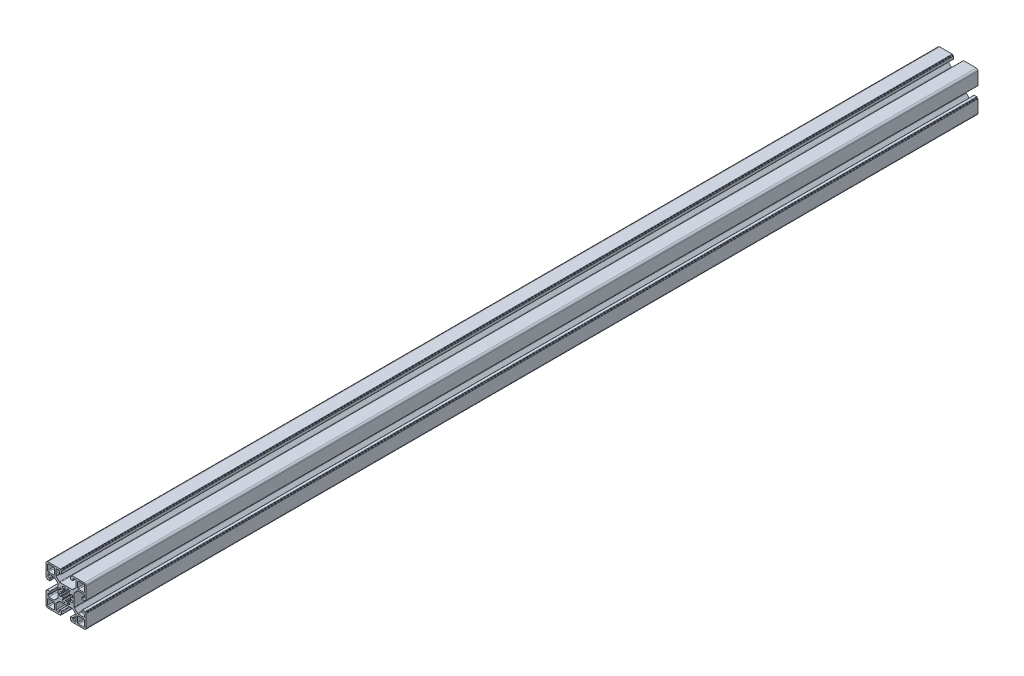
from build123d import *

# Parameters (mm, degrees)
EXTRUDE_1_DEPTH = 1000


with BuildPart() as part:
    # Эскиз1 → Бобышка-Вытянуть1 (new body)
    with BuildSketch(Plane.XY):
        with BuildLine():
            Line((-22.5, 11.25), (-22.5, 20.5))
            ThreePointArc((-22.5, 20.5), (-21.914213562, 21.914213562), (-20.5, 22.5))
            Line((-20.5, 22.5), (-11.25, 22.5))
            Line((-11.25, 22.5), (-6.4, 22.5))
            ThreePointArc((-6.4, 22.5), (-6.187867966, 22.412132034), (-6.1, 22.2))
            Line((-6.1, 22.2), (-6.1, 21.8))
            ThreePointArc((-6.1, 21.8), (-6.012132034, 21.587867966), (-5.8, 21.5))
            Line((-5.8, 21.5), (-5.4, 21.5))
            ThreePointArc((-5.4, 21.5), (-5.187867966, 21.412132034), (-5.1, 21.2))
            Line((-5.1, 21.2), (-5.1, 18.3))
            ThreePointArc((-5.1, 18.3), (-5.187867966, 18.087867966), (-5.4, 18))
            Line((-5.4, 18), (-7.3, 18))
            ThreePointArc((-7.3, 18), (-7.512132034, 18.087867966), (-7.6, 18.3))
            Line((-7.6, 18.3), (-7.6, 19.5))
            ThreePointArc((-7.6, 19.5), (-7.892893219, 20.207106781), (-8.6, 20.5))
            Line((-8.6, 20.5), (-10.25, 20.5))
            ThreePointArc((-10.25, 20.5), (-10.957106781, 20.207106781), (-11.25, 19.5))
            Line((-11.25, 19.5), (-11.25, 13.564213562))
            ThreePointArc((-11.25, 13.564213562), (-11.173879533, 13.18153013), (-10.957106781, 12.857106781))
            Line((-10.957106781, 12.857106781), (-7.542893219, 9.442893219))
            ThreePointArc((-7.542893219, 9.442893219), (-7.21846987, 9.226120467), (-6.835786438, 9.15))
            Line((-6.835786438, 9.15), (6.835786438, 9.15))
            ThreePointArc((6.835786438, 9.15), (7.21846987, 9.226120467), (7.542893219, 9.442893219))
            Line((7.542893219, 9.442893219), (10.957106781, 12.857106781))
            ThreePointArc((10.957106781, 12.857106781), (11.173879533, 13.18153013), (11.25, 13.564213562))
            Line((11.25, 13.564213562), (11.25, 19.5))
            ThreePointArc((11.25, 19.5), (10.957106781, 20.207106781), (10.25, 20.5))
            Line((10.25, 20.5), (8.6, 20.5))
            ThreePointArc((8.6, 20.5), (7.892893219, 20.207106781), (7.6, 19.5))
            Line((7.6, 19.5), (7.6, 18.3))
            ThreePointArc((7.6, 18.3), (7.512132034, 18.087867966), (7.3, 18))
            Line((7.3, 18), (5.4, 18))
            ThreePointArc((5.4, 18), (5.187867966, 18.087867966), (5.1, 18.3))
            Line((5.1, 18.3), (5.1, 21.2))
            ThreePointArc((5.1, 21.2), (5.187867966, 21.412132034), (5.4, 21.5))
            Line((5.4, 21.5), (5.8, 21.5))
            ThreePointArc((5.8, 21.5), (6.012132034, 21.587867966), (6.1, 21.8))
            Line((6.1, 21.8), (6.1, 22.2))
            ThreePointArc((6.1, 22.2), (6.187867966, 22.412132034), (6.4, 22.5))
            Line((6.4, 22.5), (11.25, 22.5))
            Line((11.25, 22.5), (20.5, 22.5))
            ThreePointArc((20.5, 22.5), (21.914213562, 21.914213562), (22.5, 20.5))
            Line((22.5, 20.5), (22.5, 11.25))
            Line((22.5, 11.25), (22.5, 6.4))
            ThreePointArc((22.5, 6.4), (22.412132034, 6.187867966), (22.2, 6.1))
            Line((22.2, 6.1), (21.8, 6.1))
            ThreePointArc((21.8, 6.1), (21.587867966, 6.012132034), (21.5, 5.8))
            Line((21.5, 5.8), (21.5, 5.4))
            ThreePointArc((21.5, 5.4), (21.412132034, 5.187867966), (21.2, 5.1))
            Line((21.2, 5.1), (18.3, 5.1))
            ThreePointArc((18.3, 5.1), (18.087867966, 5.187867966), (18, 5.4))
            Line((18, 5.4), (18, 7.3))
            ThreePointArc((18, 7.3), (18.087867966, 7.512132034), (18.3, 7.6))
            Line((18.3, 7.6), (19.5, 7.6))
            ThreePointArc((19.5, 7.6), (20.207106781, 7.892893219), (20.5, 8.6))
            Line((20.5, 8.6), (20.5, 10.25))
            ThreePointArc((20.5, 10.25), (20.207106781, 10.957106781), (19.5, 11.25))
            Line((19.5, 11.25), (13.564213562, 11.25))
            ThreePointArc((13.564213562, 11.25), (13.18153013, 11.173879533), (12.857106781, 10.957106781))
            Line((12.857106781, 10.957106781), (9.442893219, 7.542893219))
            ThreePointArc((9.442893219, 7.542893219), (9.226120467, 7.21846987), (9.15, 6.835786438))
            Line((9.15, 6.835786438), (9.15, -6.835786438))
            ThreePointArc((9.15, -6.835786438), (9.226120467, -7.21846987), (9.442893219, -7.542893219))
            Line((9.442893219, -7.542893219), (12.857106781, -10.957106781))
            ThreePointArc((12.857106781, -10.957106781), (13.18153013, -11.173879533), (13.564213562, -11.25))
            Line((13.564213562, -11.25), (19.5, -11.25))
            ThreePointArc((19.5, -11.25), (20.207106781, -10.957106781), (20.5, -10.25))
            Line((20.5, -10.25), (20.5, -8.6))
            ThreePointArc((20.5, -8.6), (20.207106781, -7.892893219), (19.5, -7.6))
            Line((19.5, -7.6), (18.3, -7.6))
            ThreePointArc((18.3, -7.6), (18.087867966, -7.512132034), (18, -7.3))
            Line((18, -7.3), (18, -5.4))
            ThreePointArc((18, -5.4), (18.087867966, -5.187867966), (18.3, -5.1))
            Line((18.3, -5.1), (21.2, -5.1))
            ThreePointArc((21.2, -5.1), (21.412132034, -5.187867966), (21.5, -5.4))
            Line((21.5, -5.4), (21.5, -5.8))
            ThreePointArc((21.5, -5.8), (21.587867966, -6.012132034), (21.8, -6.1))
            Line((21.8, -6.1), (22.2, -6.1))
            ThreePointArc((22.2, -6.1), (22.412132034, -6.187867966), (22.5, -6.4))
            Line((22.5, -6.4), (22.5, -11.25))
            Line((22.5, -11.25), (22.5, -20.5))
            ThreePointArc((22.5, -20.5), (21.914213562, -21.914213562), (20.5, -22.5))
            Line((20.5, -22.5), (11.25, -22.5))
            Line((11.25, -22.5), (6.4, -22.5))
            ThreePointArc((6.4, -22.5), (6.187867966, -22.412132034), (6.1, -22.2))
            Line((6.1, -22.2), (6.1, -21.8))
            ThreePointArc((6.1, -21.8), (6.012132034, -21.587867966), (5.8, -21.5))
            Line((5.8, -21.5), (5.4, -21.5))
            ThreePointArc((5.4, -21.5), (5.187867966, -21.412132034), (5.1, -21.2))
            Line((5.1, -21.2), (5.1, -18.3))
            ThreePointArc((5.1, -18.3), (5.187867966, -18.087867966), (5.4, -18))
            Line((5.4, -18), (7.3, -18))
            ThreePointArc((7.3, -18), (7.512132034, -18.087867966), (7.6, -18.3))
            Line((7.6, -18.3), (7.6, -19.5))
            ThreePointArc((7.6, -19.5), (7.892893219, -20.207106781), (8.6, -20.5))
            Line((8.6, -20.5), (10.25, -20.5))
            ThreePointArc((10.25, -20.5), (10.957106781, -20.207106781), (11.25, -19.5))
            Line((11.25, -19.5), (11.25, -13.564213562))
            ThreePointArc((11.25, -13.564213562), (11.173879533, -13.18153013), (10.957106781, -12.857106781))
            Line((10.957106781, -12.857106781), (7.542893219, -9.442893219))
            ThreePointArc((7.542893219, -9.442893219), (7.21846987, -9.226120467), (6.835786438, -9.15))
            Line((6.835786438, -9.15), (-6.835786438, -9.15))
            ThreePointArc((-6.835786438, -9.15), (-7.21846987, -9.226120467), (-7.542893219, -9.442893219))
            Line((-7.542893219, -9.442893219), (-10.957106781, -12.857106781))
            ThreePointArc((-10.957106781, -12.857106781), (-11.173879533, -13.18153013), (-11.25, -13.564213562))
            Line((-11.25, -13.564213562), (-11.25, -19.5))
            ThreePointArc((-11.25, -19.5), (-10.957106781, -20.207106781), (-10.25, -20.5))
            Line((-10.25, -20.5), (-8.6, -20.5))
            ThreePointArc((-8.6, -20.5), (-7.892893219, -20.207106781), (-7.6, -19.5))
            Line((-7.6, -19.5), (-7.6, -18.3))
            ThreePointArc((-7.6, -18.3), (-7.512132034, -18.087867966), (-7.3, -18))
            Line((-7.3, -18), (-5.4, -18))
            ThreePointArc((-5.4, -18), (-5.187867966, -18.087867966), (-5.1, -18.3))
            Line((-5.1, -18.3), (-5.1, -21.2))
            ThreePointArc((-5.1, -21.2), (-5.187867966, -21.412132034), (-5.4, -21.5))
            Line((-5.4, -21.5), (-5.8, -21.5))
            ThreePointArc((-5.8, -21.5), (-6.012132034, -21.587867966), (-6.1, -21.8))
            Line((-6.1, -21.8), (-6.1, -22.2))
            ThreePointArc((-6.1, -22.2), (-6.187867966, -22.412132034), (-6.4, -22.5))
            Line((-6.4, -22.5), (-11.25, -22.5))
            Line((-11.25, -22.5), (-20.5, -22.5))
            ThreePointArc((-20.5, -22.5), (-21.914213562, -21.914213562), (-22.5, -20.5))
            Line((-22.5, -20.5), (-22.5, -11.25))
            Line((-22.5, -11.25), (-22.5, -6.4))
            ThreePointArc((-22.5, -6.4), (-22.412132034, -6.187867966), (-22.2, -6.1))
            Line((-22.2, -6.1), (-21.8, -6.1))
            ThreePointArc((-21.8, -6.1), (-21.587867966, -6.012132034), (-21.5, -5.8))
            Line((-21.5, -5.8), (-21.5, -5.4))
            ThreePointArc((-21.5, -5.4), (-21.412132034, -5.187867966), (-21.2, -5.1))
            Line((-21.2, -5.1), (-18.3, -5.1))
            ThreePointArc((-18.3, -5.1), (-18.087867966, -5.187867966), (-18, -5.4))
            Line((-18, -5.4), (-18, -7.3))
            ThreePointArc((-18, -7.3), (-18.087867966, -7.512132034), (-18.3, -7.6))
            Line((-18.3, -7.6), (-19.5, -7.6))
            ThreePointArc((-19.5, -7.6), (-20.207106781, -7.892893219), (-20.5, -8.6))
            Line((-20.5, -8.6), (-20.5, -10.25))
            ThreePointArc((-20.5, -10.25), (-20.207106781, -10.957106781), (-19.5, -11.25))
            Line((-19.5, -11.25), (-13.564213562, -11.25))
            ThreePointArc((-13.564213562, -11.25), (-13.18153013, -11.173879533), (-12.857106781, -10.957106781))
            Line((-12.857106781, -10.957106781), (-9.442893219, -7.542893219))
            ThreePointArc((-9.442893219, -7.542893219), (-9.226120467, -7.21846987), (-9.15, -6.835786438))
            Line((-9.15, -6.835786438), (-9.15, 6.835786438))
            ThreePointArc((-9.15, 6.835786438), (-9.226120467, 7.21846987), (-9.442893219, 7.542893219))
            Line((-9.442893219, 7.542893219), (-12.857106781, 10.957106781))
            ThreePointArc((-12.857106781, 10.957106781), (-13.18153013, 11.173879533), (-13.564213562, 11.25))
            Line((-13.564213562, 11.25), (-19.5, 11.25))
            ThreePointArc((-19.5, 11.25), (-20.207106781, 10.957106781), (-20.5, 10.25))
            Line((-20.5, 10.25), (-20.5, 8.6))
            ThreePointArc((-20.5, 8.6), (-20.207106781, 7.892893219), (-19.5, 7.6))
            Line((-19.5, 7.6), (-18.3, 7.6))
            ThreePointArc((-18.3, 7.6), (-18.087867966, 7.512132034), (-18, 7.3))
            Line((-18, 7.3), (-18, 5.4))
            ThreePointArc((-18, 5.4), (-18.087867966, 5.187867966), (-18.3, 5.1))
            Line((-18.3, 5.1), (-21.2, 5.1))
            ThreePointArc((-21.2, 5.1), (-21.412132034, 5.187867966), (-21.5, 5.4))
            Line((-21.5, 5.4), (-21.5, 5.8))
            ThreePointArc((-21.5, 5.8), (-21.587867966, 6.012132034), (-21.8, 6.1))
            Line((-21.8, 6.1), (-22.2, 6.1))
            ThreePointArc((-22.2, 6.1), (-22.412132034, 6.187867966), (-22.5, 6.4))
            Line((-22.5, 6.4), (-22.5, 11.25))
        make_face()
        with BuildLine():
            Line((-14, 13), (-19.8, 13))
            ThreePointArc((-19.8, 13), (-20.507106781, 13.292893219), (-20.8, 14))
            Line((-20.8, 14), (-20.8, 19.8))
            ThreePointArc((-20.8, 19.8), (-20.507106781, 20.507106781), (-19.8, 20.8))
            Line((-19.8, 20.8), (-14, 20.8))
            ThreePointArc((-14, 20.8), (-13.292893219, 20.507106781), (-13, 19.8))
            Line((-13, 19.8), (-13, 14))
            ThreePointArc((-13, 14), (-13.292893219, 13.292893219), (-14, 13))
        make_face(mode=Mode.SUBTRACT)
        with BuildLine():
            Line((13, 14), (13, 19.8))
            ThreePointArc((13, 19.8), (13.292893219, 20.507106781), (14, 20.8))
            Line((14, 20.8), (19.8, 20.8))
            ThreePointArc((19.8, 20.8), (20.507106781, 20.507106781), (20.8, 19.8))
            Line((20.8, 19.8), (20.8, 14))
            ThreePointArc((20.8, 14), (20.507106781, 13.292893219), (19.8, 13))
            Line((19.8, 13), (14, 13))
            ThreePointArc((14, 13), (13.292893219, 13.292893219), (13, 14))
        make_face(mode=Mode.SUBTRACT)
        with BuildLine():
            Line((14, -13), (19.8, -13))
            ThreePointArc((19.8, -13), (20.507106781, -13.292893219), (20.8, -14))
            Line((20.8, -14), (20.8, -19.8))
            ThreePointArc((20.8, -19.8), (20.507106781, -20.507106781), (19.8, -20.8))
            Line((19.8, -20.8), (14, -20.8))
            ThreePointArc((14, -20.8), (13.292893219, -20.507106781), (13, -19.8))
            Line((13, -19.8), (13, -14))
            ThreePointArc((13, -14), (13.292893219, -13.292893219), (14, -13))
        make_face(mode=Mode.SUBTRACT)
        with BuildLine():
            Line((-13, -14), (-13, -19.8))
            ThreePointArc((-13, -19.8), (-13.292893219, -20.507106781), (-14, -20.8))
            Line((-14, -20.8), (-19.8, -20.8))
            ThreePointArc((-19.8, -20.8), (-20.507106781, -20.507106781), (-20.8, -19.8))
            Line((-20.8, -19.8), (-20.8, -14))
            ThreePointArc((-20.8, -14), (-20.507106781, -13.292893219), (-19.8, -13))
            Line((-19.8, -13), (-14, -13))
            ThreePointArc((-14, -13), (-13.292893219, -13.292893219), (-13, -14))
        make_face(mode=Mode.SUBTRACT)
        with BuildLine():
            Line((1.3637258, 7.358005976), (1.016443046, 5.484235912))
            ThreePointArc((1.016443046, 5.484235912), (0.826149864, 5.176357864), (0.477957057, 5.077554239))
            ThreePointArc((0.477957057, 5.077554239), (0, 5.1), (-0.477957057, 5.077554239))
            ThreePointArc((-0.477957057, 5.077554239), (-0.826149864, 5.176357864), (-1.016443046, 5.484235912))
            Line((-1.016443046, 5.484235912), (-1.3637258, 7.358005976))
            ThreePointArc((-1.3637258, 7.358005976), (-1.586050772, 7.688167424), (-1.979043471, 7.751347427))
            ThreePointArc((-1.979043471, 7.751347427), (-3.061467459, 7.39103626), (-4.081635271, 6.880425388))
            ThreePointArc((-4.081635271, 6.880425388), (-4.314848064, 6.557862576), (-4.238596161, 6.167195683))
            Line((-4.238596161, 6.167195683), (-3.159206632, 4.596674173))
            ThreePointArc((-3.159206632, 4.596674173), (-3.076061576, 4.244413919), (-3.252406358, 3.928339711))
            ThreePointArc((-3.252406358, 3.928339711), (-3.606244584, 3.606244584), (-3.928339711, 3.252406358))
            ThreePointArc((-3.928339711, 3.252406358), (-4.244413919, 3.076061576), (-4.596674173, 3.159206632))
            Line((-4.596674173, 3.159206632), (-6.167195683, 4.238596161))
            ThreePointArc((-6.167195683, 4.238596161), (-6.557862576, 4.314848064), (-6.880425388, 4.081635271))
            ThreePointArc((-6.880425388, 4.081635271), (-7.39103626, 3.061467459), (-7.751347427, 1.979043471))
            ThreePointArc((-7.751347427, 1.979043471), (-7.688167424, 1.586050772), (-7.358005976, 1.3637258))
            Line((-7.358005976, 1.3637258), (-5.484235912, 1.016443046))
            ThreePointArc((-5.484235912, 1.016443046), (-5.176357864, 0.826149864), (-5.077554239, 0.477957057))
            ThreePointArc((-5.077554239, 0.477957057), (-5.1, 0), (-5.077554239, -0.477957057))
            ThreePointArc((-5.077554239, -0.477957057), (-5.176357864, -0.826149864), (-5.484235912, -1.016443046))
            Line((-5.484235912, -1.016443046), (-7.358005976, -1.3637258))
            ThreePointArc((-7.358005976, -1.3637258), (-7.688167424, -1.586050772), (-7.751347427, -1.979043471))
            ThreePointArc((-7.751347427, -1.979043471), (-7.39103626, -3.061467459), (-6.880425388, -4.081635271))
            ThreePointArc((-6.880425388, -4.081635271), (-6.557862576, -4.314848064), (-6.167195683, -4.238596161))
            Line((-6.167195683, -4.238596161), (-4.596674173, -3.159206632))
            ThreePointArc((-4.596674173, -3.159206632), (-4.244413919, -3.076061576), (-3.928339711, -3.252406358))
            ThreePointArc((-3.928339711, -3.252406358), (-3.606244584, -3.606244584), (-3.252406358, -3.928339711))
            ThreePointArc((-3.252406358, -3.928339711), (-3.076061576, -4.244413919), (-3.159206632, -4.596674173))
            Line((-3.159206632, -4.596674173), (-4.238596161, -6.167195683))
            ThreePointArc((-4.238596161, -6.167195683), (-4.314848064, -6.557862576), (-4.081635271, -6.880425388))
            ThreePointArc((-4.081635271, -6.880425388), (-3.061467459, -7.39103626), (-1.979043471, -7.751347427))
            ThreePointArc((-1.979043471, -7.751347427), (-1.586050772, -7.688167424), (-1.3637258, -7.358005976))
            Line((-1.3637258, -7.358005976), (-1.016443046, -5.484235912))
            ThreePointArc((-1.016443046, -5.484235912), (-0.826149864, -5.176357864), (-0.477957057, -5.077554239))
            ThreePointArc((-0.477957057, -5.077554239), (0, -5.1), (0.477957057, -5.077554239))
            ThreePointArc((0.477957057, -5.077554239), (0.826149864, -5.176357864), (1.016443046, -5.484235912))
            Line((1.016443046, -5.484235912), (1.3637258, -7.358005976))
            ThreePointArc((1.3637258, -7.358005976), (1.586050772, -7.688167424), (1.979043471, -7.751347427))
            ThreePointArc((1.979043471, -7.751347427), (3.061467459, -7.39103626), (4.081635271, -6.880425388))
            ThreePointArc((4.081635271, -6.880425388), (4.314848064, -6.557862576), (4.238596161, -6.167195683))
            Line((4.238596161, -6.167195683), (3.159206632, -4.596674173))
            ThreePointArc((3.159206632, -4.596674173), (3.076061576, -4.244413919), (3.252406358, -3.928339711))
            ThreePointArc((3.252406358, -3.928339711), (3.606244584, -3.606244584), (3.928339711, -3.252406358))
            ThreePointArc((3.928339711, -3.252406358), (4.244413919, -3.076061576), (4.596674173, -3.159206632))
            Line((4.596674173, -3.159206632), (6.167195683, -4.238596161))
            ThreePointArc((6.167195683, -4.238596161), (6.557862576, -4.314848064), (6.880425388, -4.081635271))
            ThreePointArc((6.880425388, -4.081635271), (7.39103626, -3.061467459), (7.751347427, -1.979043471))
            ThreePointArc((7.751347427, -1.979043471), (7.688167424, -1.586050772), (7.358005976, -1.3637258))
            Line((7.358005976, -1.3637258), (5.484235912, -1.016443046))
            ThreePointArc((5.484235912, -1.016443046), (5.176357864, -0.826149864), (5.077554239, -0.477957057))
            ThreePointArc((5.077554239, -0.477957057), (5.1, 0), (5.077554239, 0.477957057))
            ThreePointArc((5.077554239, 0.477957057), (5.176357864, 0.826149864), (5.484235912, 1.016443046))
            Line((5.484235912, 1.016443046), (7.358005976, 1.3637258))
            ThreePointArc((7.358005976, 1.3637258), (7.688167424, 1.586050772), (7.751347427, 1.979043471))
            ThreePointArc((7.751347427, 1.979043471), (7.39103626, 3.061467459), (6.880425388, 4.081635271))
            ThreePointArc((6.880425388, 4.081635271), (6.557862576, 4.314848064), (6.167195683, 4.238596161))
            Line((6.167195683, 4.238596161), (4.596674173, 3.159206632))
            ThreePointArc((4.596674173, 3.159206632), (4.244413919, 3.076061576), (3.928339711, 3.252406358))
            ThreePointArc((3.928339711, 3.252406358), (3.606244584, 3.606244584), (3.252406358, 3.928339711))
            ThreePointArc((3.252406358, 3.928339711), (3.076061576, 4.244413919), (3.159206632, 4.596674173))
            Line((3.159206632, 4.596674173), (4.238596161, 6.167195683))
            ThreePointArc((4.238596161, 6.167195683), (4.314848064, 6.557862576), (4.081635271, 6.880425388))
            ThreePointArc((4.081635271, 6.880425388), (3.061467459, 7.39103626), (1.979043471, 7.751347427))
            ThreePointArc((1.979043471, 7.751347427), (1.586050772, 7.688167424), (1.3637258, 7.358005976))
        make_face(mode=Mode.SUBTRACT)
    extrude(amount=EXTRUDE_1_DEPTH)


solid = part.part
